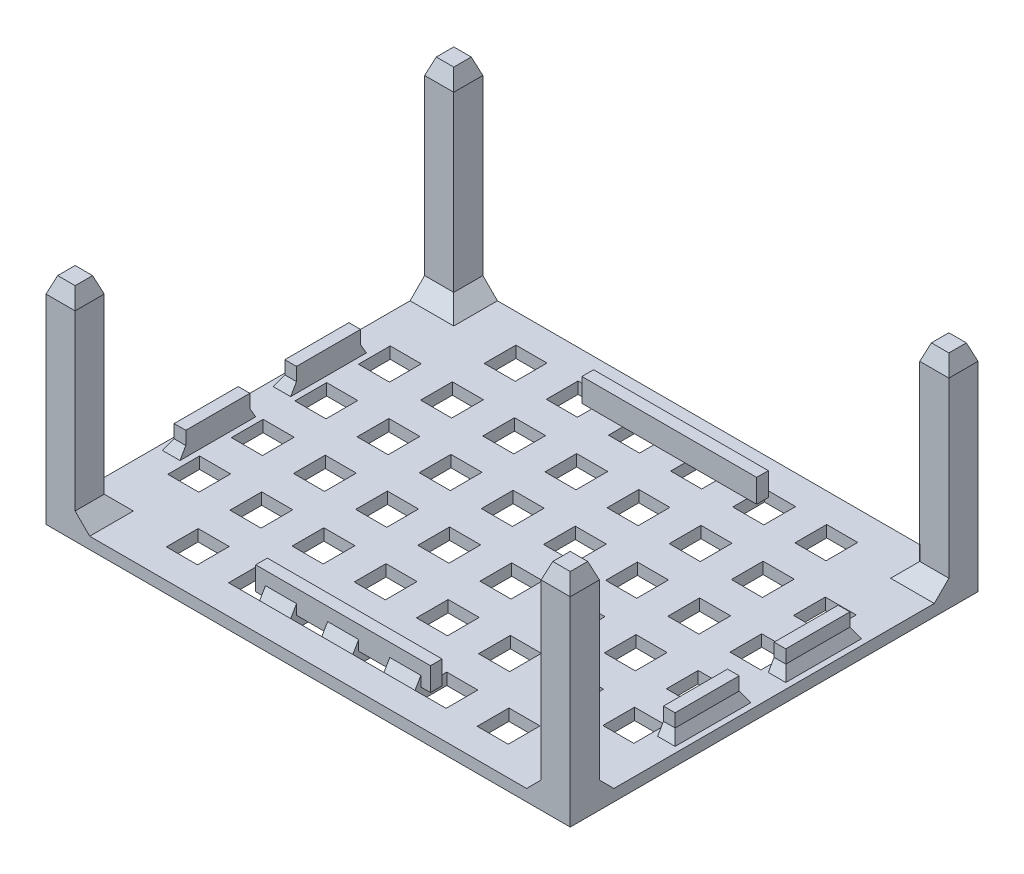
from build123d import *

# Parameters (mm, degrees)
ESBO_O1_W                = 90
ESBO_O1_H                = 70
RESSALTO_EXTRUS_O1_DEPTH = 2
ESBO_O3_W                = 5
ESBO_O3_H                = 5
RESSALTO_EXTRUS_O2_DEPTH = 35
ESBO_O4_W                = 30
ESBO_O4_H                = 2
ESBO_O4_W_2              = 2
ESBO_O4_H_2              = 11
RESSALTO_EXTRUS_O4_DEPTH = 4
ESBO_O2_W                = 5.334
ESBO_O2_H                = 5.45
ESBO_O2_W_2              = 5.31
CORTE_EXTRUS_O2_DEPTH    = 3
CHANFRO1_SIZE            = 1
CHANFRO1_SIZE2           = 2.747477419
CHANFRO1_PART_2_SIZE     = 1
CHANFRO1_PART_2_SIZE2    = 2.747477419
CHANFRO1_PART_3_SIZE     = 1
CHANFRO1_PART_3_SIZE2    = 2.747477419
CHANFRO1_PART_4_SIZE     = 1
CHANFRO1_PART_4_SIZE2    = 2.747477419
CHANFRO2_SIZE            = 2.5
CHANFRO3_SIZE            = 1
CHANFRO3_SIZE2           = 1.732050808


with BuildPart() as part:
    # Esboço1 → Ressalto-extrusão1 (new body)
    with BuildSketch(Plane(origin=(0, 0, 0), x_dir=(1, 0, 0), z_dir=(0, 1, 0))):
        Rectangle(ESBO_O1_W, ESBO_O1_H)
    extrude(amount=RESSALTO_EXTRUS_O1_DEPTH)

    # Esboço3 → Ressalto-extrusão2 (add)
    with BuildSketch(Plane(origin=(0, 2, 0), x_dir=(1, 0, 0), z_dir=(0, 1, 0))):
        with Locations((42.5, 32.5)):
            Rectangle(ESBO_O3_W, ESBO_O3_H)
        with Locations((-42.5, 32.5)):
            Rectangle(ESBO_O3_W, ESBO_O3_H)
        with Locations((42.5, -32.5)):
            Rectangle(ESBO_O3_W, ESBO_O3_H)
        with Locations((-42.5, -32.5)):
            Rectangle(ESBO_O3_W, ESBO_O3_H)
    extrude(amount=RESSALTO_EXTRUS_O2_DEPTH)

    # Esboço4 → Ressalto-extrusão4 (add)
    with BuildSketch(Plane(origin=(0, 2, 0), x_dir=(1, 0, 0), z_dir=(0, 1, 0))):
        with Locations((0, 28)):
            Rectangle(ESBO_O4_W, ESBO_O4_H)
        with Locations((0, -28)):
            Rectangle(ESBO_O4_W, ESBO_O4_H)
        with Locations((42, 9.5)):
            Rectangle(ESBO_O4_W_2, ESBO_O4_H_2)
        with Locations((42, -9.5)):
            Rectangle(ESBO_O4_W_2, ESBO_O4_H_2)
        with Locations((-42, 9.5)):
            Rectangle(ESBO_O4_W_2, ESBO_O4_H_2)
        with Locations((-42, -9.5)):
            Rectangle(ESBO_O4_W_2, ESBO_O4_H_2)
    extrude(amount=RESSALTO_EXTRUS_O4_DEPTH)

    # Esboço2 → Corte-extrusão2 (cut, through all)
    with BuildSketch(Plane(origin=(0, 2, 0), x_dir=(1, 0, 0), z_dir=(0, 1, 0))):
        with Locations((-26.663, 27.275)):
            Rectangle(ESBO_O2_W, ESBO_O2_H)
        with Locations((-37.333, 16.365)):
            Rectangle(ESBO_O2_W, ESBO_O2_H)
        with Locations((-26.663, 16.365)):
            Rectangle(ESBO_O2_W, ESBO_O2_H)
        with Locations((-37.333, 5.455)):
            Rectangle(ESBO_O2_W, ESBO_O2_H)
        with Locations((-26.663, 5.455)):
            Rectangle(ESBO_O2_W, ESBO_O2_H)
        with Locations((-37.333, -5.455)):
            Rectangle(ESBO_O2_W, ESBO_O2_H)
        with Locations((-26.663, -5.455)):
            Rectangle(ESBO_O2_W, ESBO_O2_H)
        with Locations((-37.333, -16.365)):
            Rectangle(ESBO_O2_W, ESBO_O2_H)
        with Locations((-26.663, -16.365)):
            Rectangle(ESBO_O2_W, ESBO_O2_H)
        with Locations((-15.993, -16.365)):
            Rectangle(ESBO_O2_W, ESBO_O2_H)
        with Locations((-15.993, -5.455)):
            Rectangle(ESBO_O2_W, ESBO_O2_H)
        with Locations((-15.993, 5.455)):
            Rectangle(ESBO_O2_W, ESBO_O2_H)
        with Locations((-15.993, 16.365)):
            Rectangle(ESBO_O2_W, ESBO_O2_H)
        with Locations((-15.993, 27.275)):
            Rectangle(ESBO_O2_W, ESBO_O2_H)
        with Locations((-5.323, 27.275)):
            Rectangle(ESBO_O2_W, ESBO_O2_H)
        with Locations((-5.323, 16.365)):
            Rectangle(ESBO_O2_W, ESBO_O2_H)
        with Locations((-5.323, 5.455)):
            Rectangle(ESBO_O2_W, ESBO_O2_H)
        with Locations((-5.323, -5.455)):
            Rectangle(ESBO_O2_W, ESBO_O2_H)
        with Locations((-5.323, -16.365)):
            Rectangle(ESBO_O2_W, ESBO_O2_H)
        with Locations((5.347, -16.365)):
            Rectangle(ESBO_O2_W, ESBO_O2_H)
        with Locations((5.347, -5.455)):
            Rectangle(ESBO_O2_W, ESBO_O2_H)
        with Locations((5.347, 5.455)):
            Rectangle(ESBO_O2_W, ESBO_O2_H)
        with Locations((5.347, 16.365)):
            Rectangle(ESBO_O2_W, ESBO_O2_H)
        with Locations((5.347, 27.275)):
            Rectangle(ESBO_O2_W, ESBO_O2_H)
        with Locations((16.017, 27.275)):
            Rectangle(ESBO_O2_W, ESBO_O2_H)
        with Locations((16.017, 16.365)):
            Rectangle(ESBO_O2_W, ESBO_O2_H)
        with Locations((16.017, 5.455)):
            Rectangle(ESBO_O2_W, ESBO_O2_H)
        with Locations((16.017, -5.455)):
            Rectangle(ESBO_O2_W, ESBO_O2_H)
        with Locations((16.017, -16.365)):
            Rectangle(ESBO_O2_W, ESBO_O2_H)
        with Locations((26.687, -16.365)):
            Rectangle(ESBO_O2_W, ESBO_O2_H)
        with Locations((26.687, -5.455)):
            Rectangle(ESBO_O2_W, ESBO_O2_H)
        with Locations((26.687, 5.455)):
            Rectangle(ESBO_O2_W, ESBO_O2_H)
        with Locations((26.687, 16.365)):
            Rectangle(ESBO_O2_W, ESBO_O2_H)
        with Locations((26.687, 27.275)):
            Rectangle(ESBO_O2_W, ESBO_O2_H)
        with Locations((37.345, 16.365)):
            Rectangle(ESBO_O2_W_2, ESBO_O2_H)
        with Locations((37.345, 5.455)):
            Rectangle(ESBO_O2_W_2, ESBO_O2_H)
        with Locations((37.345, -5.455)):
            Rectangle(ESBO_O2_W_2, ESBO_O2_H)
        with Locations((37.345, -16.365)):
            Rectangle(ESBO_O2_W_2, ESBO_O2_H)
        with Locations((-26.663, -27.275)):
            Rectangle(ESBO_O2_W, ESBO_O2_H)
        with Locations((-15.993, -27.275)):
            Rectangle(ESBO_O2_W, ESBO_O2_H)
        with Locations((-5.323, -27.275)):
            Rectangle(ESBO_O2_W, ESBO_O2_H)
        with Locations((5.347, -27.275)):
            Rectangle(ESBO_O2_W, ESBO_O2_H)
        with Locations((16.017, -27.275)):
            Rectangle(ESBO_O2_W, ESBO_O2_H)
        with Locations((26.687, -27.275)):
            Rectangle(ESBO_O2_W, ESBO_O2_H)
    extrude(amount=-CORTE_EXTRUS_O2_DEPTH, mode=Mode.SUBTRACT)

    # Chanfro1
    chanfro1_edges = [part.edges().sort_by_distance(p)[0] for p in [
        (-45, 37, -32.5),
        (-42.5, 37, -30),
        (-40, 37, -32.5),
        (-42.5, 37, -35),
    ]]
    chanfro1_side = [part.faces().sort_by_distance(p)[0] for p in [
        (-42.5, 37, -32.5),
    ]]
    chamfer(chanfro1_edges, length=CHANFRO1_SIZE, length2=CHANFRO1_SIZE2, reference=chanfro1_side[0])

    # Chanfro1 part 2
    chanfro1_part_2_edges = [part.edges().sort_by_distance(p)[0] for p in [
        (40, 37, -32.5),
        (42.5, 37, -30),
        (45, 37, -32.5),
        (42.5, 37, -35),
    ]]
    chanfro1_part_2_side = [part.faces().sort_by_distance(p)[0] for p in [
        (42.5, 37, -32.5),
    ]]
    chamfer(chanfro1_part_2_edges, length=CHANFRO1_PART_2_SIZE, length2=CHANFRO1_PART_2_SIZE2, reference=chanfro1_part_2_side[0])

    # Chanfro1 part 3
    chanfro1_part_3_edges = [part.edges().sort_by_distance(p)[0] for p in [
        (40, 37, 32.5),
        (42.5, 37, 35),
        (45, 37, 32.5),
        (42.5, 37, 30),
    ]]
    chanfro1_part_3_side = [part.faces().sort_by_distance(p)[0] for p in [
        (42.5, 37, 32.5),
    ]]
    chamfer(chanfro1_part_3_edges, length=CHANFRO1_PART_3_SIZE, length2=CHANFRO1_PART_3_SIZE2, reference=chanfro1_part_3_side[0])

    # Chanfro1 part 4
    chanfro1_part_4_edges = [part.edges().sort_by_distance(p)[0] for p in [
        (-45, 37, 32.5),
        (-42.5, 37, 35),
        (-40, 37, 32.5),
        (-42.5, 37, 30),
    ]]
    chanfro1_part_4_side = [part.faces().sort_by_distance(p)[0] for p in [
        (-42.5, 37, 32.5),
    ]]
    chamfer(chanfro1_part_4_edges, length=CHANFRO1_PART_4_SIZE, length2=CHANFRO1_PART_4_SIZE2, reference=chanfro1_part_4_side[0])

    # Chanfro2
    chanfro2_edges = [part.edges().sort_by_distance(p)[0] for p in [
        (-42.5, 2, -30),
        (-40, 2, -32.5),
        (40, 2, -32.5),
        (42.5, 2, -30),
        (40, 2, 32.5),
        (42.5, 2, 30),
        (-40, 2, 32.5),
        (-42.5, 2, 30),
    ]]
    chamfer(chanfro2_edges, length=CHANFRO2_SIZE)

    # Chanfro3
    chanfro3_edges = [part.edges().sort_by_distance(p)[0] for p in [
        (-10.658, 2, -29),
        (0.012, 2, -29),
        (10.682, 2, -29),
        (-42, 2, -15),
        (-43, 2, -9.5),
        (-42, 2, -4),
        (-42, 2, 4),
        (-43, 2, 9.5),
        (-42, 2, 15),
        (42, 2, -15),
        (42, 2, -4),
        (43, 2, -9.5),
        (42, 2, 4),
        (42, 2, 15),
        (43, 2, 9.5),
        (10.682, 2, 29),
        (-10.658, 2, 29),
        (0.012, 2, 29),
    ]]
    chanfro3_side = [part.faces().sort_by_distance(p)[0] for p in [
        (0.001037115, 2, 0),
    ]]
    chamfer(chanfro3_edges, length=CHANFRO3_SIZE, length2=CHANFRO3_SIZE2, reference=chanfro3_side[0])


solid = part.part
